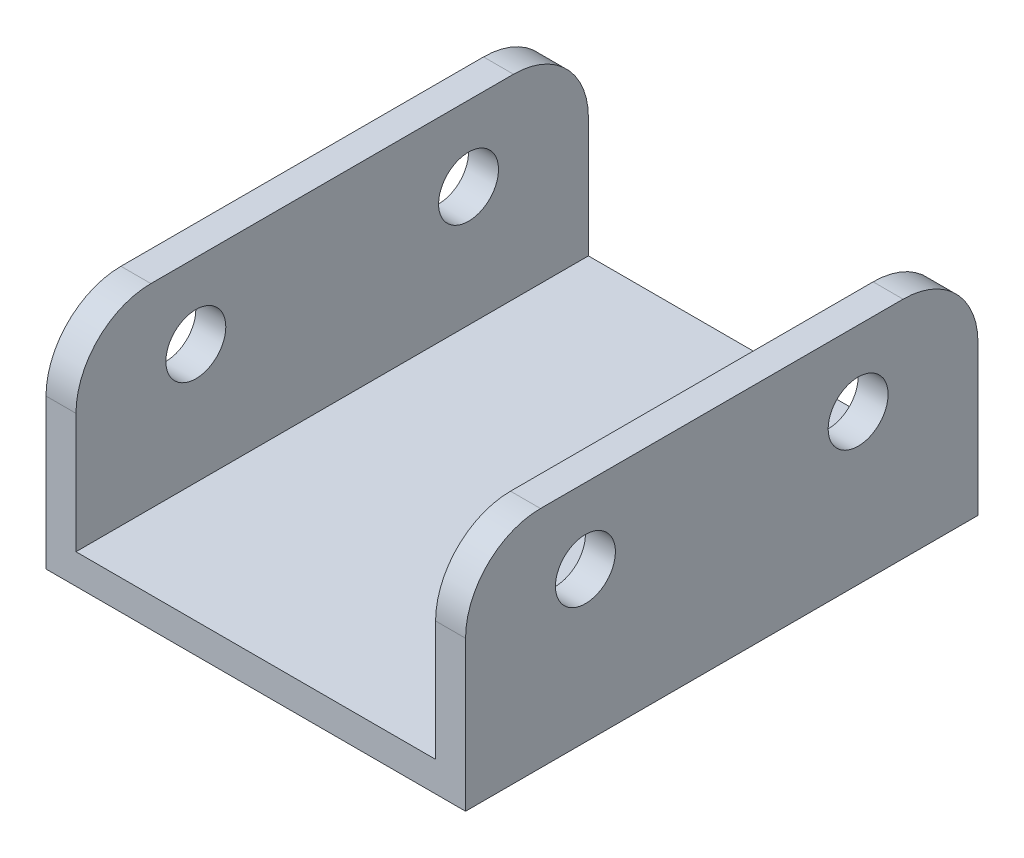
from build123d import *

# Parameters (mm, degrees)
BOSS_EXTRUDE1_DEPTH     = 17.1
SKETCH2_R               = 2
CUT_EXTRUDE1_DEPTH      = 1
CUT_EXTRUDE1_DEPTH_BACK = 29
FILLET1_R               = 5


with BuildPart() as part:
    # Sketch1 → Boss-Extrude1 (new body, symmetric)
    with BuildSketch(Plane.XY):
        Polygon((-14, 14), (-12, 14), (-12, 1), (12, 1), (12, 14), (14, 14), (14, -1), (-14, -1), align=None)
    extrude(amount=BOSS_EXTRUDE1_DEPTH, both=True)

    # Sketch2 → Cut-Extrude1 (cut, two sides)
    with BuildSketch(Plane(origin=(14, 0, 0), x_dir=(0, 0, -1), z_dir=(1, 0, 0))) as cut_extrude1_sk:
        with Locations((-9.1, 9)):
            Circle(SKETCH2_R)
        with Locations((9.1, 9)):
            Circle(SKETCH2_R)
    extrude(amount=CUT_EXTRUDE1_DEPTH, mode=Mode.SUBTRACT)
    extrude(cut_extrude1_sk.sketch, amount=-CUT_EXTRUDE1_DEPTH_BACK, mode=Mode.SUBTRACT)

    # Fillet1
    fillet1_edges = [part.edges().sort_by_distance(p)[0] for p in [
        (13, 14, -17.1),
        (13, 14, 17.1),
        (-13, 14, 17.1),
        (-13, 14, -17.1),
    ]]
    fillet(fillet1_edges, radius=FILLET1_R)


solid = part.part
